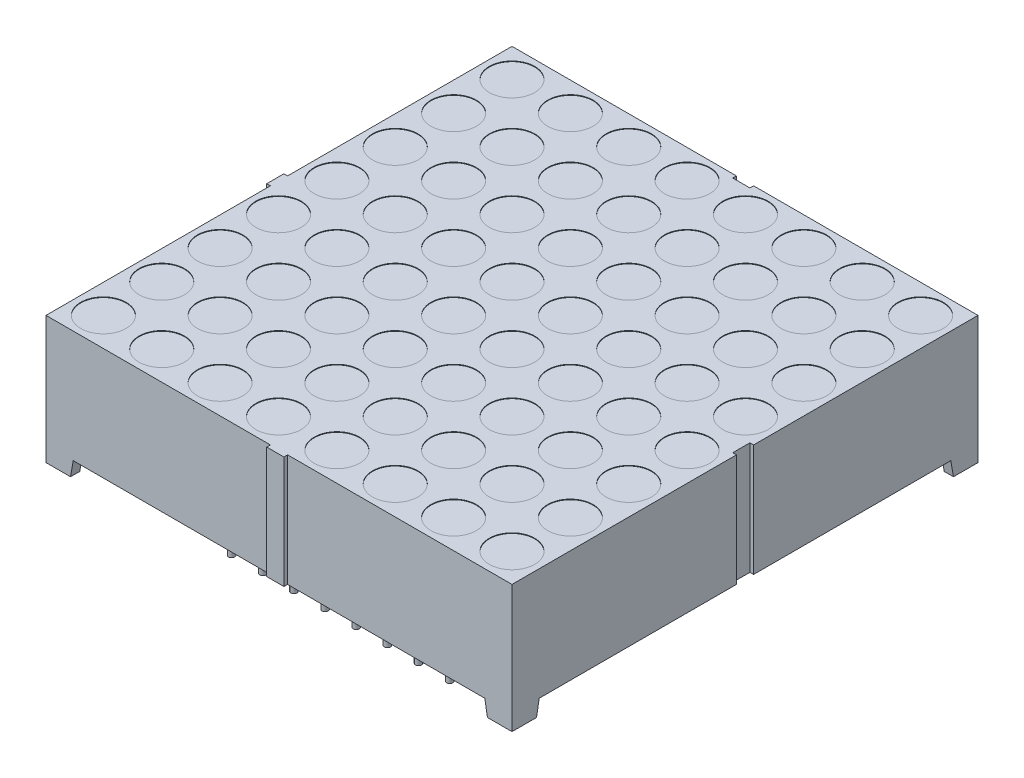
from build123d import *
from build123d.topology import SkipClean

# Parameters (mm, degrees)
EXTRUDE1_DEPTH     = 19
CUT_EXTRUDE1_DEPTH = 39
SKETCH2_R          = 1.85
CUT_EXTRUDE2_DEPTH = 0.05
SKETCH4_R          = 0.25
EXTRUDE2_DEPTH     = 1.25
SKETCH4_3_R        = 0.25
EXTRUDE3_DEPTH     = 4
SKETCH4_4_W        = 1.470408726
SKETCH4_4_H        = 1.470408726
CUT_EXTRUDE3_DEPTH = 1.25
SKETCH2_4_W        = 0.3
SKETCH2_4_H        = 1.4
SKETCH2_4_W_2      = 1.4
SKETCH2_4_H_2      = 0.3
CUT_EXTRUDE5_DEPTH = 15.4
SKETCH2_5_W        = 0.3
SKETCH2_5_H        = 1.4
SKETCH2_5_W_2      = 1.4
SKETCH2_5_H_2      = 0.3
EXTRUDE4_DEPTH     = 9.15
SKETCH5_W          = 0.026582278
SKETCH5_H          = 0.025316456
CUT_EXTRUDE6_DEPTH = 0.01


with BuildPart() as part:
    # Sketch1 → Extrude1 (new body, symmetric)
    with BuildSketch(Plane(origin=(0, 0, 0), x_dir=(0, 0, -1), z_dir=(1, 0, 0))):
        Polygon((19, 5.2), (-19, 5.2), (14.432692308, -3.95), (16.779591274, -3.95), (16.898590362, -4.624877362), (19, -5.2), align=None)
        Polygon((14.432692308, -3.95), (-19, 5.2), (-19, -5.2), (-17, -5.2), (-16.779591274, -3.95), align=None)
        Polygon((19, -5.2), (16.898590362, -4.624877362), (17, -5.2), align=None)
    extrude(amount=EXTRUDE1_DEPTH, both=True)

    # Sketch3 → Cut-Extrude1 (cut, through all)
    with BuildSketch(Plane.XY.offset(19)):
        Polygon((-16.779591274, -3.95), (-17, -5.2), (17, -5.2), (16.779591274, -3.95), align=None)
    extrude(amount=-CUT_EXTRUDE1_DEPTH, mode=Mode.SUBTRACT)

    # Sketch2 → Cut-Extrude2 (cut)
    with BuildSketch(Plane(origin=(0, 5.2, 0), x_dir=(-1, 0, 0), z_dir=(0, 1, 0))):
        with Locations(Location((7.14, 11.9, 0), (0, 0, 90))):  # turned: the seam where the file's is
            Circle(SKETCH2_R)
        with Locations(Location((7.14, -7.14, 0), (0, 0, 90))):  # turned: the seam where the file's is
            Circle(SKETCH2_R)
        with Locations(Location((7.14, -2.38, 0), (0, 0, 90))):  # turned: the seam where the file's is
            Circle(SKETCH2_R)
        with Locations(Location((7.14, -11.9, 0), (0, 0, 90))):  # turned: the seam where the file's is
            Circle(SKETCH2_R)
        with Locations(Location((7.14, 2.38, 0), (0, 0, 90))):  # turned: the seam where the file's is
            Circle(SKETCH2_R)
        with Locations(Location((7.14, 16.66, 0), (0, 0, 90))):  # turned: the seam where the file's is
            Circle(SKETCH2_R)
        with Locations(Location((7.14, 7.14, 0), (0, 0, 90))):  # turned: the seam where the file's is
            Circle(SKETCH2_R)
        with Locations(Location((2.38, -2.38, 0), (0, 0, 90))):  # turned: the seam where the file's is
            Circle(SKETCH2_R)
        with Locations(Location((2.38, 2.38, 0), (0, 0, 90))):  # turned: the seam where the file's is
            Circle(SKETCH2_R)
        with Locations(Location((2.38, 11.9, 0), (0, 0, 90))):  # turned: the seam where the file's is
            Circle(SKETCH2_R)
        with Locations(Location((2.38, 16.66, 0), (0, 0, 90))):  # turned: the seam where the file's is
            Circle(SKETCH2_R)
        with Locations(Location((2.38, -7.14, 0), (0, 0, 90))):  # turned: the seam where the file's is
            Circle(SKETCH2_R)
        with Locations(Location((2.38, -11.9, 0), (0, 0, 90))):  # turned: the seam where the file's is
            Circle(SKETCH2_R)
        with Locations(Location((2.38, 7.14, 0), (0, 0, 90))):  # turned: the seam where the file's is
            Circle(SKETCH2_R)
        with Locations(Location((11.9, -2.38, 0), (0, 0, 90))):  # turned: the seam where the file's is
            Circle(SKETCH2_R)
        with Locations(Location((11.9, 2.38, 0), (0, 0, 90))):  # turned: the seam where the file's is
            Circle(SKETCH2_R)
        with Locations(Location((11.9, 11.9, 0), (0, 0, 90))):  # turned: the seam where the file's is
            Circle(SKETCH2_R)
        with Locations(Location((11.9, 16.66, 0), (0, 0, 90))):  # turned: the seam where the file's is
            Circle(SKETCH2_R)
        with Locations(Location((11.9, -7.14, 0), (0, 0, 90))):  # turned: the seam where the file's is
            Circle(SKETCH2_R)
        with Locations(Location((11.9, -11.9, 0), (0, 0, 90))):  # turned: the seam where the file's is
            Circle(SKETCH2_R)
        with Locations(Location((11.9, 7.14, 0), (0, 0, 90))):  # turned: the seam where the file's is
            Circle(SKETCH2_R)
        with Locations(Location((16.66, -2.38, 0), (0, 0, 90))):  # turned: the seam where the file's is
            Circle(SKETCH2_R)
        with Locations(Location((16.66, 2.38, 0), (0, 0, 90))):  # turned: the seam where the file's is
            Circle(SKETCH2_R)
        with Locations(Location((16.66, 11.9, 0), (0, 0, 90))):  # turned: the seam where the file's is
            Circle(SKETCH2_R)
        with Locations(Location((16.66, 16.66, 0), (0, 0, 90))):  # turned: the seam where the file's is
            Circle(SKETCH2_R)
        with Locations(Location((16.66, -7.14, 0), (0, 0, 90))):  # turned: the seam where the file's is
            Circle(SKETCH2_R)
        with Locations(Location((16.66, -11.9, 0), (0, 0, 90))):  # turned: the seam where the file's is
            Circle(SKETCH2_R)
        with Locations(Location((16.66, 7.14, 0), (0, 0, 90))):  # turned: the seam where the file's is
            Circle(SKETCH2_R)
        with Locations(Location((-7.14, -16.66, 0), (0, 0, 90))):  # turned: the seam where the file's is
            Circle(SKETCH2_R)
        with Locations(Location((-11.9, -16.66, 0), (0, 0, 90))):  # turned: the seam where the file's is
            Circle(SKETCH2_R)
        with Locations(Location((-11.9, 7.14, 0), (0, 0, 90))):  # turned: the seam where the file's is
            Circle(SKETCH2_R)
        with Locations(Location((-11.9, -11.9, 0), (0, 0, 90))):  # turned: the seam where the file's is
            Circle(SKETCH2_R)
        with Locations(Location((-11.9, -7.14, 0), (0, 0, 90))):  # turned: the seam where the file's is
            Circle(SKETCH2_R)
        with Locations(Location((-11.9, 16.66, 0), (0, 0, 90))):  # turned: the seam where the file's is
            Circle(SKETCH2_R)
        with Locations(Location((-11.9, 11.9, 0), (0, 0, 90))):  # turned: the seam where the file's is
            Circle(SKETCH2_R)
        with Locations(Location((-11.9, 2.38, 0), (0, 0, 90))):  # turned: the seam where the file's is
            Circle(SKETCH2_R)
        with Locations(Location((-11.9, -2.38, 0), (0, 0, 90))):  # turned: the seam where the file's is
            Circle(SKETCH2_R)
        with Locations(Location((-2.38, 7.14, 0), (0, 0, 90))):  # turned: the seam where the file's is
            Circle(SKETCH2_R)
        with Locations(Location((-2.38, -11.9, 0), (0, 0, 90))):  # turned: the seam where the file's is
            Circle(SKETCH2_R)
        with Locations(Location((-2.38, -7.14, 0), (0, 0, 90))):  # turned: the seam where the file's is
            Circle(SKETCH2_R)
        with Locations(Location((-2.38, 16.66, 0), (0, 0, 90))):  # turned: the seam where the file's is
            Circle(SKETCH2_R)
        with Locations(Location((-2.38, 11.9, 0), (0, 0, 90))):  # turned: the seam where the file's is
            Circle(SKETCH2_R)
        with Locations(Location((-2.38, 2.38, 0), (0, 0, 90))):  # turned: the seam where the file's is
            Circle(SKETCH2_R)
        with Locations(Location((-2.38, -2.38, 0), (0, 0, 90))):  # turned: the seam where the file's is
            Circle(SKETCH2_R)
        with Locations(Location((-7.14, 7.14, 0), (0, 0, 90))):  # turned: the seam where the file's is
            Circle(SKETCH2_R)
        with Locations(Location((-7.14, 16.66, 0), (0, 0, 90))):  # turned: the seam where the file's is
            Circle(SKETCH2_R)
        with Locations(Location((-7.14, 2.38, 0), (0, 0, 90))):  # turned: the seam where the file's is
            Circle(SKETCH2_R)
        with Locations(Location((-7.14, -11.9, 0), (0, 0, 90))):  # turned: the seam where the file's is
            Circle(SKETCH2_R)
        with Locations(Location((-7.14, -2.38, 0), (0, 0, 90))):  # turned: the seam where the file's is
            Circle(SKETCH2_R)
        with Locations(Location((-7.14, -7.14, 0), (0, 0, 90))):  # turned: the seam where the file's is
            Circle(SKETCH2_R)
        with Locations(Location((-7.14, 11.9, 0), (0, 0, 90))):  # turned: the seam where the file's is
            Circle(SKETCH2_R)
        with Locations(Location((16.66, -16.66, 0), (0, 0, 90))):  # turned: the seam where the file's is
            Circle(SKETCH2_R)
        with Locations(Location((11.9, -16.66, 0), (0, 0, 90))):  # turned: the seam where the file's is
            Circle(SKETCH2_R)
        with Locations(Location((-2.38, -16.66, 0), (0, 0, 90))):  # turned: the seam where the file's is
            Circle(SKETCH2_R)
        with Locations(Location((2.38, -16.66, 0), (0, 0, 90))):  # turned: the seam where the file's is
            Circle(SKETCH2_R)
        with Locations(Location((7.14, -16.66, 0), (0, 0, 90))):  # turned: the seam where the file's is
            Circle(SKETCH2_R)
        with Locations(Location((-16.66, -16.66, 0), (0, 0, 90))):  # turned: the seam where the file's is
            Circle(SKETCH2_R)
        with Locations(Location((-16.66, 7.14, 0), (0, 0, 90))):  # turned: the seam where the file's is
            Circle(SKETCH2_R)
        with Locations(Location((-16.66, -11.9, 0), (0, 0, 90))):  # turned: the seam where the file's is
            Circle(SKETCH2_R)
        with Locations(Location((-16.66, -7.14, 0), (0, 0, 90))):  # turned: the seam where the file's is
            Circle(SKETCH2_R)
        with Locations(Location((-16.66, 16.66, 0), (0, 0, 90))):  # turned: the seam where the file's is
            Circle(SKETCH2_R)
        with Locations(Location((-16.66, 11.9, 0), (0, 0, 90))):  # turned: the seam where the file's is
            Circle(SKETCH2_R)
        with Locations(Location((-16.66, 2.38, 0), (0, 0, 90))):  # turned: the seam where the file's is
            Circle(SKETCH2_R)
        with Locations(Location((-16.66, -2.38, 0), (0, 0, 90))):  # turned: the seam where the file's is
            Circle(SKETCH2_R)
    extrude(amount=-CUT_EXTRUDE2_DEPTH, mode=Mode.SUBTRACT)

    # Sketch4 → Extrude2 (add)
    with BuildSketch(Plane.XZ.offset(5.2)):
        with Locations((-8.89, 13.97)):
            Circle(SKETCH4_R)
        with Locations(Location((-6.35, 13.97, 0), (0, 0, 270))):  # turned: the seam where the file's is
            Circle(SKETCH4_R)
        with Locations(Location((-3.81, 13.97, 0), (0, 0, 270))):  # turned: the seam where the file's is
            Circle(SKETCH4_R)
        with Locations(Location((6.35, 13.97, 0), (0, 0, 270))):  # turned: the seam where the file's is
            Circle(SKETCH4_R)
        with Locations(Location((-1.27, 13.97, 0), (0, 0, 270))):  # turned: the seam where the file's is
            Circle(SKETCH4_R)
        with Locations(Location((1.27, 13.97, 0), (0, 0, 270))):  # turned: the seam where the file's is
            Circle(SKETCH4_R)
        with Locations(Location((3.81, 13.97, 0), (0, 0, 270))):  # turned: the seam where the file's is
            Circle(SKETCH4_R)
        with Locations(Location((3.81, -13.97, 0), (0, 0, 270))):  # turned: the seam where the file's is
            Circle(SKETCH4_R)
        with Locations(Location((1.27, -13.97, 0), (0, 0, 270))):  # turned: the seam where the file's is
            Circle(SKETCH4_R)
        with Locations(Location((-1.27, -13.97, 0), (0, 0, 270))):  # turned: the seam where the file's is
            Circle(SKETCH4_R)
        with Locations(Location((6.35, -13.97, 0), (0, 0, 270))):  # turned: the seam where the file's is
            Circle(SKETCH4_R)
        with Locations(Location((-3.81, -13.97, 0), (0, 0, 270))):  # turned: the seam where the file's is
            Circle(SKETCH4_R)
        with Locations(Location((-6.35, -13.97, 0), (0, 0, 270))):  # turned: the seam where the file's is
            Circle(SKETCH4_R)
        with Locations(Location((-8.89, -13.97, 0), (0, 0, 270))):  # turned: the seam where the file's is
            Circle(SKETCH4_R)
        with Locations(Location((8.89, 13.97, 0), (0, 0, 270))):  # turned: the seam where the file's is
            Circle(SKETCH4_R)
        with Locations(Location((8.89, -13.97, 0), (0, 0, 270))):  # turned: the seam where the file's is
            Circle(SKETCH4_R)
    extrude(amount=-EXTRUDE2_DEPTH)

    # Sketch4_3 → Extrude3 (add)
    with SkipClean():  # keep this step's faces unmerged: merging them makes the solid invalid here
        with BuildSketch(Plane.XZ.offset(5.2)):
            with Locations((-8.89, 13.97)):
                Circle(SKETCH4_3_R)
            with Locations((-6.35, 13.97)):
                Circle(SKETCH4_3_R)
            with Locations((-3.81, 13.97)):
                Circle(SKETCH4_3_R)
            with Locations((6.35, 13.97)):
                Circle(SKETCH4_3_R)
            with Locations((-1.27, 13.97)):
                Circle(SKETCH4_3_R)
            with Locations((1.27, 13.97)):
                Circle(SKETCH4_3_R)
            with Locations(Location((3.81, 13.97, 0), (0, 0, 270))):  # turned: the seam where the file's is
                Circle(SKETCH4_3_R)
            with Locations(Location((3.81, -13.97, 0), (0, 0, 180))):  # turned: the seam where the file's is
                Circle(SKETCH4_3_R)
            with Locations(Location((1.27, -13.97, 0), (0, 0, 180))):  # turned: the seam where the file's is
                Circle(SKETCH4_3_R)
            with Locations(Location((-1.27, -13.97, 0), (0, 0, 180))):  # turned: the seam where the file's is
                Circle(SKETCH4_3_R)
            with Locations(Location((6.35, -13.97, 0), (0, 0, 180))):  # turned: the seam where the file's is
                Circle(SKETCH4_3_R)
            with Locations(Location((-3.81, -13.97, 0), (0, 0, 270))):  # turned: the seam where the file's is
                Circle(SKETCH4_3_R)
            with Locations(Location((-6.35, -13.97, 0), (0, 0, 270))):  # turned: the seam where the file's is
                Circle(SKETCH4_3_R)
            with Locations(Location((-8.89, -13.97, 0), (0, 0, 270))):  # turned: the seam where the file's is
                Circle(SKETCH4_3_R)
            with Locations(Location((8.89, 13.97, 0), (0, 0, 270))):  # turned: the seam where the file's is
                Circle(SKETCH4_3_R)
            with Locations(Location((8.89, -13.97, 0), (0, 0, 270))):  # turned: the seam where the file's is
                Circle(SKETCH4_3_R)
        extrude(amount=EXTRUDE3_DEPTH)

    # Sketch4_4 → Cut-Extrude3 (cut)
    with SkipClean():  # keep this step's faces unmerged: merging them makes the solid invalid here
        with BuildSketch(Plane.XZ.offset(5.2)):
            with Locations((-17.514795637, 17.514795637)):
                Rectangle(SKETCH4_4_W, SKETCH4_4_H)
            with Locations((17.514795637, 17.514795637)):
                Rectangle(SKETCH4_4_W, SKETCH4_4_H)
            with Locations((17.514795637, -17.514795637)):
                Rectangle(SKETCH4_4_W, SKETCH4_4_H)
            with Locations((-17.514795637, -17.514795637)):
                Rectangle(SKETCH4_4_W, SKETCH4_4_H)
        extrude(amount=-CUT_EXTRUDE3_DEPTH, mode=Mode.SUBTRACT)

    # Sketch2_4 → Cut-Extrude5 (cut, through all)
    with SkipClean():  # keep this step's faces unmerged: merging them makes the solid invalid here
        with BuildSketch(Plane(origin=(0, 5.2, 0), x_dir=(-1, 0, 0), z_dir=(0, 1, 0))):
            with Locations((-18.85, 0)):
                Rectangle(SKETCH2_4_W, SKETCH2_4_H)
            with Locations((0, -18.85)):
                Rectangle(SKETCH2_4_W_2, SKETCH2_4_H_2)
        extrude(amount=-CUT_EXTRUDE5_DEPTH, mode=Mode.SUBTRACT)

    # Sketch2_5 → Extrude4 (add)
    with SkipClean():  # keep this step's faces unmerged: merging them makes the solid invalid here
        with BuildSketch(Plane(origin=(0, 5.2, 0), x_dir=(-1, 0, 0), z_dir=(0, 1, 0))):
            with Locations((19.15, 0)):
                Rectangle(SKETCH2_5_W, SKETCH2_5_H)
            with Locations((0, 19.15)):
                Rectangle(SKETCH2_5_W_2, SKETCH2_5_H_2)
        extrude(amount=-EXTRUDE4_DEPTH)

    # Sketch5 → Cut-Extrude6 (cut)
    with SkipClean():  # keep this step's faces unmerged: merging them makes the solid invalid here
        with BuildSketch(Plane.XZ.offset(3.95)):
            Polygon((-16.512571084, 0.692786076), (-16.587254628, 0.716243355), (-16.587254628, 0.740986235), (-16.536918394, 0.757402374), (-16.587254628, 0.772928481), (-16.587254628, 0.798660285), (-16.512571084, 0.8219), (-16.512571084, 0.796721994), (-16.56405447, 0.783727532), (-16.512571084, 0.767311393), (-16.512571084, 0.745812184), (-16.56405447, 0.729494937), (-16.512571084, 0.716678481), align=None)
            Polygon((-16.512571084, 0.558608861), (-16.587254628, 0.58206614), (-16.587254628, 0.606809019), (-16.536918394, 0.623225159), (-16.587254628, 0.638751266), (-16.587254628, 0.66448307), (-16.512571084, 0.687722785), (-16.512571084, 0.662544779), (-16.56405447, 0.649550317), (-16.512571084, 0.633134178), (-16.512571084, 0.611634969), (-16.56405447, 0.595317722), (-16.512571084, 0.582501266), align=None)
            Polygon((-16.512571084, 0.424431646), (-16.587254628, 0.447888924), (-16.587254628, 0.472631804), (-16.536918394, 0.489047943), (-16.587254628, 0.504574051), (-16.587254628, 0.530305855), (-16.512571084, 0.55354557), (-16.512571084, 0.528367564), (-16.56405447, 0.515373102), (-16.512571084, 0.498956962), (-16.512571084, 0.477457754), (-16.56405447, 0.461140507), (-16.512571084, 0.448324051), align=None)
            with Locations((-16.573963489, 0.396583545)):
                Rectangle(SKETCH5_W, SKETCH5_H)
            with BuildLine():
                add(Edge.make_bspline(
                    [(-16.556083742, 0.280127848), (-16.557305876, 0.280164347), (-16.559705739, 0.280236017), (-16.563213426, 0.280845603), (-16.56653773, 0.281839571), (-16.569701876, 0.28321191), (-16.572671364, 0.285005366), (-16.575474256, 0.287188637), (-16.5780788, 0.28977752), (-16.580515175, 0.292724324), (-16.582697286, 0.296021267), (-16.58460332, 0.299618981), (-16.586197991, 0.303499008), (-16.587537056, 0.307647219), (-16.588525489, 0.312093766), (-16.589249477, 0.316811264), (-16.589722795, 0.321804692), (-16.589764762, 0.325228269), (-16.589786274, 0.32698307)],
                    knots=[0, 0, 0, 0, 0.907312236, 1.78165839, 2.635367075, 3.479697475, 4.336364812, 5.205276731, 6.11257575, 7.058770404, 8.040786331, 9.044147278, 10.078219212, 11.153049307, 12.278104542, 13.457648573, 14.696882856, 16, 16, 16, 16], degree=3))
                add(Edge.make_bspline(
                    [(-16.589786274, 0.32698307), (-16.589762202, 0.329001325), (-16.589715577, 0.332910508), (-16.589286978, 0.338574033), (-16.588640839, 0.34384207), (-16.587674297, 0.348737785), (-16.586473532, 0.353342384), (-16.58518224, 0.357775652), (-16.583717825, 0.362056964), (-16.582617667, 0.364830053), (-16.582072666, 0.366203798)],
                    knots=[0, 0, 0, 0, 1.203215828, 2.33052265, 3.384689099, 4.366106119, 5.303329643, 6.221311756, 7.118865988, 8, 8, 8, 8], degree=3))
                Line((-16.582072666, 0.366203798), (-16.558140704, 0.366203798))
                Line((-16.558140704, 0.366203798), (-16.558140704, 0.363355697))
                add(Edge.make_bspline(
                    [(-16.558140704, 0.363355697), (-16.559222159, 0.361990382), (-16.56137872, 0.35926777), (-16.564141325, 0.354834537), (-16.566543488, 0.350186891), (-16.56851749, 0.34534142), (-16.570103814, 0.340444576), (-16.571197342, 0.335569198), (-16.57194469, 0.330803611), (-16.572025197, 0.327645041), (-16.572064755, 0.326093038)],
                    knots=[0, 0, 0, 0, 1.030622468, 2.055194264, 3.087043286, 4.125157485, 5.149848264, 6.130935704, 7.081611712, 8, 8, 8, 8], degree=3))
                add(Edge.make_bspline(
                    [(-16.572064755, 0.326093038), (-16.57206386, 0.32566426), (-16.572061945, 0.324746278), (-16.571933102, 0.323278241), (-16.571839939, 0.321619642), (-16.571630721, 0.319840776), (-16.571412138, 0.318049958), (-16.571031818, 0.316395298), (-16.570669979, 0.314891659), (-16.570301802, 0.313985177), (-16.570126464, 0.313553481)],
                    knots=[0, 0, 0, 0, 0.806378557, 1.726393851, 2.771014456, 3.931269413, 5.096090628, 6.161710732, 7.124547685, 8, 8, 8, 8], degree=3))
                add(Edge.make_bspline(
                    [(-16.570126464, 0.313553481), (-16.56989864, 0.313073695), (-16.569450918, 0.312130811), (-16.568633311, 0.310835892), (-16.567762009, 0.30965322), (-16.56679659, 0.308591759), (-16.565618682, 0.307741492), (-16.564217826, 0.307113291), (-16.562567525, 0.306770197), (-16.561392515, 0.306730903), (-16.560771242, 0.306710127)],
                    knots=[0, 0, 0, 0, 1.024407818, 2.013179384, 2.949802342, 3.859052226, 4.77034807, 5.732977883, 6.801339628, 8, 8, 8, 8], degree=3))
                add(Edge.make_bspline(
                    [(-16.560771242, 0.306710127), (-16.560225346, 0.306741569), (-16.559151953, 0.306803392), (-16.557623957, 0.307385184), (-16.55620208, 0.308268082), (-16.554941365, 0.309555104), (-16.553783927, 0.311149181), (-16.55281363, 0.313104918), (-16.551933556, 0.315357897), (-16.551516287, 0.317002356), (-16.55129735, 0.31786519)],
                    knots=[0, 0, 0, 0, 0.825212765, 1.622611382, 2.449701629, 3.348069183, 4.336544339, 5.428209675, 6.6506027, 8, 8, 8, 8], degree=3))
                add(Edge.make_bspline(
                    [(-16.55129735, 0.31786519), (-16.550849609, 0.319833917), (-16.549932419, 0.323866825), (-16.548785312, 0.330014934), (-16.547519239, 0.336145162), (-16.546309698, 0.340103874), (-16.545719818, 0.342034494)],
                    knots=[0, 0, 0, 0, 0.976104583, 1.999535498, 3.024395274, 4, 4, 4, 4], degree=3))
                add(Edge.make_bspline(
                    [(-16.545719818, 0.342034494), (-16.545366825, 0.34307301), (-16.544679692, 0.345094578), (-16.543518067, 0.347986122), (-16.542248115, 0.350647235), (-16.540892984, 0.353087345), (-16.539418986, 0.355286667), (-16.537885597, 0.357281857), (-16.536231759, 0.359025383), (-16.534499839, 0.360573067), (-16.532647837, 0.361896381), (-16.5307037, 0.363051131), (-16.528643235, 0.364026767), (-16.526481947, 0.36483565), (-16.524203078, 0.365452723), (-16.521826204, 0.365873979), (-16.519342844, 0.366172368), (-16.517648491, 0.366193179), (-16.5167839, 0.366203798)],
                    knots=[0, 0, 0, 0, 1.287286806, 2.505824366, 3.654938963, 4.74627059, 5.778586806, 6.75996495, 7.696030012, 8.595059759, 9.482019644, 10.363222407, 11.245851011, 12.154256429, 13.068444161, 14.012503255, 14.985824751, 16, 16, 16, 16], degree=3))
                add(Edge.make_bspline(
                    [(-16.5167839, 0.366203798), (-16.515627756, 0.366166496), (-16.513352483, 0.366093086), (-16.510023439, 0.365491658), (-16.506874702, 0.364465068), (-16.503871239, 0.363079004), (-16.501058153, 0.361250376), (-16.498379606, 0.359065582), (-16.495908014, 0.356441534), (-16.493607681, 0.353464413), (-16.491528282, 0.350177029), (-16.489697726, 0.346638045), (-16.488161074, 0.342868756), (-16.48688718, 0.338883209), (-16.485932509, 0.33466474), (-16.485213578, 0.330227508), (-16.484800396, 0.325553719), (-16.484749146, 0.322362297), (-16.484722983, 0.32073307)],
                    knots=[0, 0, 0, 0, 0.894990994, 1.761326291, 2.609044902, 3.454222546, 4.315366365, 5.200560057, 6.125081389, 7.100429509, 8.110379559, 9.133447974, 10.182136699, 11.259192205, 12.370181258, 13.528580438, 14.738335141, 16, 16, 16, 16], degree=3))
                add(Edge.make_bspline(
                    [(-16.484722983, 0.32073307), (-16.484745174, 0.319064383), (-16.484789519, 0.315729838), (-16.485167497, 0.310748396), (-16.485722725, 0.305787894), (-16.486564431, 0.300924063), (-16.487540848, 0.296233508), (-16.488636643, 0.291820272), (-16.489874608, 0.287740812), (-16.490828953, 0.285167148), (-16.491289438, 0.283925317)],
                    knots=[0, 0, 0, 0, 1.065403572, 2.129000689, 3.188532477, 4.251604565, 5.279552602, 6.247508681, 7.154397237, 8, 8, 8, 8], degree=3))
                Line((-16.491289438, 0.283925317), (-16.513836907, 0.283925317))
                Line((-16.513836907, 0.283925317), (-16.513836907, 0.28675364))
                add(Edge.make_bspline(
                    [(-16.513836907, 0.28675364), (-16.51303656, 0.287826544), (-16.51139983, 0.290020663), (-16.509316158, 0.293680299), (-16.507358292, 0.297638535), (-16.505674133, 0.301917366), (-16.504214652, 0.306376393), (-16.503195486, 0.310959352), (-16.502553676, 0.315585515), (-16.502480901, 0.318687226), (-16.502444502, 0.320238608)],
                    knots=[0, 0, 0, 0, 0.892283326, 1.824742884, 2.804416662, 3.836872171, 4.8899239, 5.931447339, 6.965372909, 8, 8, 8, 8], degree=3))
                add(Edge.make_bspline(
                    [(-16.502444502, 0.320238608), (-16.502465954, 0.321334276), (-16.502508856, 0.323525492), (-16.50289954, 0.326793701), (-16.503530434, 0.330035762), (-16.504349716, 0.332076284), (-16.504758584, 0.333094621)],
                    knots=[0, 0, 0, 0, 0.999146175, 1.998183711, 3.000980573, 4, 4, 4, 4], degree=3))
                add(Edge.make_bspline(
                    [(-16.504758584, 0.333094621), (-16.504960051, 0.333528124), (-16.50536285, 0.334394841), (-16.506135414, 0.335601486), (-16.507064225, 0.336706155), (-16.508116217, 0.337698232), (-16.50927259, 0.33856663), (-16.510547417, 0.339181981), (-16.511910331, 0.339557854), (-16.512845562, 0.339600012), (-16.513322666, 0.339621519)],
                    knots=[0, 0, 0, 0, 1.00524851, 2.009826503, 3.004679593, 4.035271301, 5.048246368, 6.034938417, 6.997532266, 8, 8, 8, 8], degree=3))
                add(Edge.make_bspline(
                    [(-16.513322666, 0.339621519), (-16.513960831, 0.339587081), (-16.515180307, 0.339521273), (-16.516896103, 0.338914689), (-16.518374537, 0.337929855), (-16.519369457, 0.336769251), (-16.520066895, 0.335652121), (-16.520577406, 0.334616461), (-16.521060764, 0.333407234), (-16.521558233, 0.332035987), (-16.52204942, 0.33049966), (-16.522524967, 0.328791103), (-16.522974263, 0.326908386), (-16.523260453, 0.325592511), (-16.523409691, 0.324906329)],
                    knots=[0, 0, 0, 0, 1.173816843, 2.243057204, 3.312297565, 4.415174738, 5.03266065, 5.73970059, 6.541434878, 7.433956553, 8.430083051, 9.515931566, 10.70464786, 12, 12, 12, 12], degree=3))
                add(Edge.make_bspline(
                    [(-16.523409691, 0.324906329), (-16.523785753, 0.32307354), (-16.524524631, 0.319472514), (-16.525628119, 0.314071331), (-16.526903088, 0.308568557), (-16.528051891, 0.304903231), (-16.528650989, 0.302991773)],
                    knots=[0, 0, 0, 0, 0.995744513, 1.956417928, 2.934277412, 4, 4, 4, 4], degree=3))
                add(Edge.make_bspline(
                    [(-16.528650989, 0.302991773), (-16.528970233, 0.302045218), (-16.529594726, 0.300193605), (-16.530681008, 0.297552975), (-16.531854991, 0.295105916), (-16.533096522, 0.292838883), (-16.534440488, 0.290764913), (-16.535863135, 0.288870231), (-16.537390044, 0.287186413), (-16.539003272, 0.285688847), (-16.540713372, 0.284369687), (-16.542552445, 0.283237389), (-16.544501247, 0.282265161), (-16.546587447, 0.281495556), (-16.548782034, 0.280877536), (-16.551113402, 0.280454439), (-16.553557779, 0.280160455), (-16.555232356, 0.280138839), (-16.556083742, 0.280127848)],
                    knots=[0, 0, 0, 0, 1.237467875, 2.420686895, 3.535046182, 4.599015201, 5.620884487, 6.594603852, 7.531477383, 8.433220087, 9.318759595, 10.202828513, 11.105163009, 12.01247538, 12.953896178, 13.926381251, 14.945733412, 16, 16, 16, 16], degree=3))
            make_face()
            with BuildLine():
                Line((-16.587254628, 0.187722785), (-16.587254628, 0.211773418))
                Line((-16.587254628, 0.211773418), (-16.57942235, 0.211773418))
                add(Edge.make_bspline(
                    [(-16.57942235, 0.211773418), (-16.580230908, 0.212866727), (-16.581789797, 0.21497461), (-16.583870014, 0.218147635), (-16.58564528, 0.221173726), (-16.587204501, 0.224087216), (-16.588379886, 0.22710942), (-16.589207953, 0.230340934), (-16.589707725, 0.233843758), (-16.589759509, 0.236270653), (-16.589786274, 0.237525)],
                    knots=[0, 0, 0, 0, 1.150872466, 2.218865267, 3.209461834, 4.120482262, 5.012764827, 5.946708227, 6.938749913, 8, 8, 8, 8], degree=3))
                add(Edge.make_bspline(
                    [(-16.589786274, 0.237525), (-16.589763555, 0.238541352), (-16.589719314, 0.240520483), (-16.589374437, 0.243397723), (-16.588836785, 0.246105351), (-16.588029194, 0.24862039), (-16.587063391, 0.25098438), (-16.585783433, 0.253121929), (-16.584353259, 0.255125531), (-16.582646213, 0.256907204), (-16.58074848, 0.258522825), (-16.57861602, 0.259905375), (-16.576283095, 0.261083086), (-16.573731241, 0.262024184), (-16.570972937, 0.262779273), (-16.56799369, 0.263303206), (-16.564806562, 0.263623798), (-16.562611432, 0.263655737), (-16.561483267, 0.263672152)],
                    knots=[0, 0, 0, 0, 1.109008058, 2.159558935, 3.158726032, 4.116861086, 5.039058877, 5.938775559, 6.82970133, 7.720510853, 8.624361809, 9.544451588, 10.487360536, 11.471068125, 12.508000841, 13.604731202, 14.768976642, 16, 16, 16, 16], degree=3))
                Line((-16.561483267, 0.263672152), (-16.512571084, 0.263672152))
                Line((-16.512571084, 0.263672152), (-16.512571084, 0.239621519))
                Line((-16.512571084, 0.239621519), (-16.550150198, 0.239621519))
                add(Edge.make_bspline(
                    [(-16.550150198, 0.239621519), (-16.551066669, 0.239619884), (-16.552820884, 0.239616753), (-16.555326691, 0.239534414), (-16.557594864, 0.239413514), (-16.559636892, 0.239274809), (-16.561483643, 0.239021792), (-16.563149804, 0.238644084), (-16.564669406, 0.238173258), (-16.565576107, 0.237708939), (-16.56601254, 0.237485443)],
                    knots=[0, 0, 0, 0, 1.361401701, 2.605856924, 3.723918663, 4.735739235, 5.645738665, 6.489217889, 7.27279937, 8, 8, 8, 8], degree=3))
                add(Edge.make_bspline(
                    [(-16.56601254, 0.237485443), (-16.566411254, 0.237255437), (-16.567195094, 0.236803263), (-16.568201272, 0.235882973), (-16.569045539, 0.234804231), (-16.569701568, 0.233526627), (-16.570200517, 0.232040079), (-16.570540753, 0.230312148), (-16.570756255, 0.228326786), (-16.570784163, 0.226917768), (-16.570798932, 0.226172152)],
                    knots=[0, 0, 0, 0, 0.849138082, 1.669332372, 2.503455908, 3.370611167, 4.311442699, 5.394692208, 6.621337967, 8, 8, 8, 8], degree=3))
                add(Edge.make_bspline(
                    [(-16.570798932, 0.226172152), (-16.570781575, 0.225630868), (-16.570745888, 0.224517951), (-16.570513442, 0.222806638), (-16.570156767, 0.221010061), (-16.569496911, 0.218495479), (-16.568310732, 0.215328851), (-16.566956325, 0.21296955), (-16.56626966, 0.211773418)],
                    knots=[0, 0, 0, 0, 0.638127216, 1.312033637, 2.033062677, 2.79661882, 4.375931797, 6, 6, 6, 6], degree=3))
                Line((-16.56626966, 0.211773418), (-16.512571084, 0.211773418))
                Line((-16.512571084, 0.211773418), (-16.512571084, 0.187722785))
                Line((-16.512571084, 0.187722785), (-16.587254628, 0.187722785))
            make_face()
            with BuildLine():
                Line((-16.587254628, 0.090254431), (-16.587254628, 0.114305064))
                Line((-16.587254628, 0.114305064), (-16.549675514, 0.114305064))
                add(Edge.make_bspline(
                    [(-16.549675514, 0.114305064), (-16.548145471, 0.114329578), (-16.545094446, 0.114378462), (-16.541332036, 0.114660585), (-16.538489711, 0.115039107), (-16.53665183, 0.115408763), (-16.535103691, 0.115840463), (-16.534217932, 0.116252743), (-16.533813172, 0.11644114)],
                    knots=[0, 0, 0, 0, 1.709124929, 3.408128882, 4.211124727, 4.91016634, 5.501986363, 6, 6, 6, 6], degree=3))
                add(Edge.make_bspline(
                    [(-16.533813172, 0.11644114), (-16.533415119, 0.116685602), (-16.532634679, 0.117164906), (-16.531621666, 0.11810223), (-16.530792825, 0.119196116), (-16.530111275, 0.120466886), (-16.529640694, 0.121958083), (-16.529247464, 0.123674823), (-16.529080555, 0.125661441), (-16.529045395, 0.127068711), (-16.52902678, 0.127813766)],
                    knots=[0, 0, 0, 0, 0.86006424, 1.686277094, 2.52783008, 3.38194165, 4.331801563, 5.402842185, 6.624978739, 8, 8, 8, 8], degree=3))
                add(Edge.make_bspline(
                    [(-16.52902678, 0.127813766), (-16.529083517, 0.128945588), (-16.529199371, 0.131256682), (-16.529910878, 0.134118876), (-16.530729837, 0.13644948), (-16.531488668, 0.138302004), (-16.53246011, 0.140210635), (-16.533181932, 0.141490047), (-16.533556052, 0.142153165)],
                    knots=[0, 0, 0, 0, 1.338371478, 2.732853438, 3.468019217, 4.261884641, 5.099136535, 6, 6, 6, 6], degree=3))
                Line((-16.533556052, 0.142153165), (-16.587254628, 0.142153165))
                Line((-16.587254628, 0.142153165), (-16.587254628, 0.166203798))
                Line((-16.587254628, 0.166203798), (-16.512571084, 0.166203798))
                Line((-16.512571084, 0.166203798), (-16.512571084, 0.142153165))
                Line((-16.512571084, 0.142153165), (-16.520403362, 0.142153165))
                add(Edge.make_bspline(
                    [(-16.520403362, 0.142153165), (-16.519597211, 0.141095758), (-16.518027989, 0.139037454), (-16.515987568, 0.135858216), (-16.514188799, 0.132774318), (-16.512675982, 0.129721308), (-16.511469207, 0.126606353), (-16.510658218, 0.123343595), (-16.510114416, 0.119927189), (-16.510064722, 0.117590473), (-16.510039438, 0.116401583)],
                    knots=[0, 0, 0, 0, 1.126119141, 2.192057864, 3.198061997, 4.149848529, 5.076251285, 6.021887753, 6.99356175, 8, 8, 8, 8], degree=3))
                add(Edge.make_bspline(
                    [(-16.510039438, 0.116401583), (-16.510064827, 0.115405311), (-16.510114391, 0.113460412), (-16.510424101, 0.110625652), (-16.510974765, 0.107954231), (-16.511772595, 0.105461957), (-16.512758207, 0.103119337), (-16.513989721, 0.100957392), (-16.515448145, 0.098965322), (-16.517109147, 0.097136921), (-16.518998874, 0.095506103), (-16.521116138, 0.094089067), (-16.523459235, 0.092909085), (-16.526019543, 0.091938373), (-16.528784653, 0.09116395), (-16.531780618, 0.090648819), (-16.534984797, 0.090295035), (-16.53720084, 0.090268236), (-16.538342445, 0.090254431)],
                    knots=[0, 0, 0, 0, 1.08848837, 2.124922927, 3.110950502, 4.063144162, 4.979605775, 5.882838355, 6.774625441, 7.671951181, 8.57587277, 9.494821853, 10.448322275, 11.435533005, 12.482327682, 13.580118324, 14.753386918, 16, 16, 16, 16], degree=3))
                Line((-16.538342445, 0.090254431), (-16.587254628, 0.090254431))
            make_face()
            Polygon((-16.587254628, -0.004682278), (-16.587254628, 0.067469621), (-16.487254628, 0.067469621), (-16.487254628, 0.042153165), (-16.568267286, 0.042153165), (-16.568267286, -0.004682278), align=None)
            Polygon((-16.587254628, -0.09202405), (-16.587254628, -0.019872152), (-16.487254628, -0.019872152), (-16.487254628, -0.09202405), (-16.50624197, -0.09202405), (-16.50624197, -0.045188607), (-16.523963489, -0.045188607), (-16.523963489, -0.088226582), (-16.542950831, -0.088226582), (-16.542950831, -0.045188607), (-16.568267286, -0.045188607), (-16.568267286, -0.09202405), align=None)
            with BuildLine():
                add(Edge.make_bspline(
                    [(-16.537353521, -0.208479746), (-16.538501209, -0.208460431), (-16.540774096, -0.208422179), (-16.544138902, -0.208126988), (-16.547404578, -0.207600962), (-16.550588826, -0.206921781), (-16.553667754, -0.205999275), (-16.556675331, -0.204917561), (-16.559580825, -0.203607916), (-16.562382259, -0.202103063), (-16.565054362, -0.200453591), (-16.567574571, -0.198678842), (-16.569957788, -0.196833063), (-16.572152682, -0.19484375), (-16.574194702, -0.192764568), (-16.576085516, -0.19058904), (-16.577788947, -0.188283975), (-16.578811831, -0.186676813), (-16.579323457, -0.185872943)],
                    knots=[0, 0, 0, 0, 1.105570398, 2.18947457, 3.250358341, 4.290584537, 5.323553275, 6.344225964, 7.367641686, 8.3905646, 9.405808457, 10.390761353, 11.358902336, 12.307789878, 13.241960776, 14.165076779, 15.082208636, 16, 16, 16, 16], degree=3))
                add(Edge.make_bspline(
                    [(-16.579323457, -0.185872943), (-16.580035597, -0.184633714), (-16.581463509, -0.182148935), (-16.5831321, -0.1781651), (-16.584536216, -0.174039618), (-16.58559064, -0.169689231), (-16.586317684, -0.165042222), (-16.586878491, -0.160040813), (-16.58718025, -0.154633223), (-16.58722927, -0.150898328), (-16.587254628, -0.148966297)],
                    knots=[0, 0, 0, 0, 0.896288622, 1.797150563, 2.705281913, 3.629615989, 4.602417572, 5.655716007, 6.787320449, 8, 8, 8, 8], degree=3))
                Line((-16.587254628, -0.148966297), (-16.587254628, -0.113543038))
                Line((-16.587254628, -0.113543038), (-16.487254628, -0.113543038))
                Line((-16.487254628, -0.113543038), (-16.487254628, -0.149975))
                add(Edge.make_bspline(
                    [(-16.487254628, -0.149975), (-16.487271239, -0.151953731), (-16.48730328, -0.15577046), (-16.48772087, -0.161287299), (-16.488317694, -0.166392507), (-16.489242565, -0.171077855), (-16.49035791, -0.17537786), (-16.491717039, -0.179303335), (-16.493215746, -0.182915109), (-16.49448944, -0.185093951), (-16.495106685, -0.186149841)],
                    knots=[0, 0, 0, 0, 1.267175336, 2.444223962, 3.542125549, 4.557526608, 5.500936977, 6.385043188, 7.217374394, 8, 8, 8, 8], degree=3))
                add(Edge.make_bspline(
                    [(-16.495106685, -0.186149841), (-16.495643226, -0.187000795), (-16.496710139, -0.188692919), (-16.498491992, -0.191094134), (-16.500448069, -0.193323561), (-16.502499887, -0.195452064), (-16.504702774, -0.197431882), (-16.507041481, -0.199275081), (-16.509519575, -0.200978898), (-16.512129044, -0.202536862), (-16.514859096, -0.203957677), (-16.517732155, -0.205146983), (-16.520710685, -0.206196332), (-16.523819648, -0.207001868), (-16.527027484, -0.207699782), (-16.530368828, -0.208134517), (-16.533821316, -0.208421128), (-16.536166206, -0.208460042), (-16.537353521, -0.208479746)],
                    knots=[0, 0, 0, 0, 0.964065863, 1.917049184, 2.86229036, 3.805247319, 4.749389377, 5.698846072, 6.657678277, 7.629829384, 8.610569287, 9.604676042, 10.607940105, 11.6349849, 12.681042988, 13.752616828, 14.862056989, 16, 16, 16, 16], degree=3))
            make_face()
            with BuildLine():
                add(Edge.make_bspline(
                    [(-16.537195293, -0.181897468), (-16.536390533, -0.181887227), (-16.534811949, -0.18186714), (-16.532496434, -0.181675572), (-16.530266784, -0.181416516), (-16.528132092, -0.180985462), (-16.526072522, -0.180485815), (-16.524115027, -0.179843666), (-16.522235454, -0.179119269), (-16.520457966, -0.178237631), (-16.518749583, -0.177263994), (-16.517164068, -0.176116501), (-16.515651182, -0.174868163), (-16.514223197, -0.173489877), (-16.512917301, -0.171946937), (-16.511687225, -0.170286834), (-16.510558899, -0.168486476), (-16.509898849, -0.167213488), (-16.509564755, -0.166569145)],
                    knots=[0, 0, 0, 0, 1.152093354, 2.259898929, 3.325467225, 4.364140538, 5.376172865, 6.358396836, 7.312077728, 8.257828931, 9.196960457, 10.124297759, 11.056236784, 12.004246951, 12.961658638, 13.947279359, 14.960983522, 16, 16, 16, 16], degree=3))
                add(Edge.make_bspline(
                    [(-16.509564755, -0.166569145), (-16.509258043, -0.165894248), (-16.508650118, -0.164556553), (-16.507918926, -0.162485731), (-16.50734609, -0.160396347), (-16.506915232, -0.158194748), (-16.506593301, -0.155724988), (-16.506396043, -0.152799406), (-16.506253873, -0.149343497), (-16.506246122, -0.146856782), (-16.50624197, -0.145524841)],
                    knots=[0, 0, 0, 0, 0.826967603, 1.639107464, 2.447640171, 3.242670507, 4.14065217, 5.225198036, 6.513753944, 8, 8, 8, 8], degree=3))
                Line((-16.50624197, -0.145524841), (-16.50624197, -0.138859493))
                Line((-16.50624197, -0.138859493), (-16.568267286, -0.138859493))
                Line((-16.568267286, -0.138859493), (-16.568267286, -0.145524841))
                add(Edge.make_bspline(
                    [(-16.568267286, -0.145524841), (-16.568262537, -0.146283048), (-16.568253367, -0.147746814), (-16.568210305, -0.149863057), (-16.568163418, -0.151828854), (-16.568046955, -0.153633724), (-16.567974309, -0.155292409), (-16.56779593, -0.15677919), (-16.56765375, -0.15812168), (-16.567386027, -0.159689276), (-16.566969844, -0.161542442), (-16.566291666, -0.163703702), (-16.56544127, -0.165844237), (-16.564756303, -0.16723281), (-16.564410483, -0.16793386)],
                    knots=[0, 0, 0, 0, 1.186793418, 2.291178421, 3.313283093, 4.264083014, 5.122158624, 5.910777728, 6.607099052, 7.234812932, 8.398911528, 9.577194775, 10.776795607, 12, 12, 12, 12], degree=3))
                add(Edge.make_bspline(
                    [(-16.564410483, -0.16793386), (-16.564068966, -0.168518976), (-16.563395452, -0.169672902), (-16.562261378, -0.171296407), (-16.561053653, -0.172804125), (-16.559765202, -0.174200137), (-16.558376961, -0.175463436), (-16.556910419, -0.176615455), (-16.555362441, -0.177645904), (-16.553168923, -0.178881293), (-16.550137987, -0.180104539), (-16.5461706, -0.181144081), (-16.541810837, -0.181780953), (-16.538773219, -0.181857635), (-16.537195293, -0.181897468)],
                    knots=[0, 0, 0, 0, 0.755160452, 1.489275589, 2.205657296, 2.907868421, 3.605098304, 4.296256403, 4.985378686, 5.676536785, 7.100390329, 8.614249252, 10.241231541, 12, 12, 12, 12], degree=3))
            make_face(mode=Mode.SUBTRACT)
            with Locations((-16.573963489, -0.240125316)):
                Rectangle(SKETCH5_W, SKETCH5_H)
            with BuildLine():
                add(Edge.make_bspline(
                    [(-16.589786274, -0.314769303), (-16.589764463, -0.313179191), (-16.589721651, -0.310058054), (-16.589244734, -0.305486713), (-16.588527039, -0.30112154), (-16.587506132, -0.296975232), (-16.586158636, -0.29306144), (-16.5845057, -0.289397803), (-16.582520516, -0.285990946), (-16.580941307, -0.283932299), (-16.580154153, -0.282906171)],
                    knots=[0, 0, 0, 0, 1.123670284, 2.205584497, 3.245308791, 4.249063313, 5.220352711, 6.167273909, 7.086481357, 8, 8, 8, 8], degree=3))
                add(Edge.make_bspline(
                    [(-16.580154153, -0.282906171), (-16.579299379, -0.281954423), (-16.577593136, -0.280054608), (-16.57462171, -0.277588675), (-16.571338665, -0.27546559), (-16.567736443, -0.273680037), (-16.563819714, -0.272249114), (-16.559575052, -0.27122598), (-16.555014271, -0.270606734), (-16.551866338, -0.270539569), (-16.55024909, -0.270505063)],
                    knots=[0, 0, 0, 0, 0.916457077, 1.82937027, 2.759194969, 3.714948755, 4.706655623, 5.743329475, 6.840637961, 8, 8, 8, 8], degree=3))
                add(Edge.make_bspline(
                    [(-16.55024909, -0.270505063), (-16.548545863, -0.270543823), (-16.545244783, -0.270618946), (-16.540472596, -0.271282706), (-16.536054915, -0.272352318), (-16.532003007, -0.273889876), (-16.528309815, -0.275820318), (-16.52493798, -0.278084811), (-16.521895056, -0.280705337), (-16.520149617, -0.282712475), (-16.519275989, -0.283717088)],
                    knots=[0, 0, 0, 0, 1.171797512, 2.271099083, 3.308930235, 4.294129479, 5.24602549, 6.17106565, 7.084581485, 8, 8, 8, 8], degree=3))
                add(Edge.make_bspline(
                    [(-16.519275989, -0.283717088), (-16.518507403, -0.284742959), (-16.516960947, -0.28680709), (-16.515060247, -0.290210595), (-16.513465461, -0.29383381), (-16.512217817, -0.297663381), (-16.511263911, -0.30163619), (-16.510540068, -0.305695849), (-16.510119509, -0.309842102), (-16.510066257, -0.312632303), (-16.510039438, -0.3140375)],
                    knots=[0, 0, 0, 0, 0.952130878, 1.915761808, 2.890227217, 3.891541892, 4.905612075, 5.925811839, 6.955400088, 8, 8, 8, 8], degree=3))
                add(Edge.make_bspline(
                    [(-16.510039438, -0.3140375), (-16.510056441, -0.315284218), (-16.510089873, -0.31773569), (-16.510411982, -0.321336737), (-16.510945101, -0.324791278), (-16.511683704, -0.32809621), (-16.512575307, -0.331270156), (-16.513614448, -0.334320333), (-16.514747716, -0.337280143), (-16.515632251, -0.339180712), (-16.516071875, -0.340125316)],
                    knots=[0, 0, 0, 0, 1.107648782, 2.178012834, 3.209595929, 4.211695017, 5.185427128, 6.137685403, 7.07440854, 8, 8, 8, 8], degree=3))
                Line((-16.516071875, -0.340125316), (-16.536621717, -0.340125316))
                Line((-16.536621717, -0.340125316), (-16.536621717, -0.336782753))
                add(Edge.make_bspline(
                    [(-16.536621717, -0.336782753), (-16.536204497, -0.336283209), (-16.535302783, -0.335203573), (-16.53388203, -0.333417157), (-16.532352437, -0.331268215), (-16.531460491, -0.329614679), (-16.53098485, -0.328732911)],
                    knots=[0, 0, 0, 0, 0.792826818, 1.713491785, 2.780691913, 4, 4, 4, 4], degree=3))
                add(Edge.make_bspline(
                    [(-16.53098485, -0.328732911), (-16.530542892, -0.327804976), (-16.529637032, -0.325903031), (-16.528804198, -0.323347026), (-16.528236472, -0.321155024), (-16.52798005, -0.319337488), (-16.527790489, -0.317403868), (-16.527770982, -0.316068626), (-16.527760957, -0.315382436)],
                    knots=[0, 0, 0, 0, 1.332524827, 2.731214173, 3.480270227, 4.267952375, 5.109889624, 6, 6, 6, 6], degree=3))
                add(Edge.make_bspline(
                    [(-16.527760957, -0.315382436), (-16.527780507, -0.314616881), (-16.527818393, -0.31313327), (-16.528095449, -0.310971762), (-16.528573707, -0.30895335), (-16.529213807, -0.307050128), (-16.53010142, -0.305312065), (-16.531135057, -0.303685225), (-16.532360859, -0.302192966), (-16.533801801, -0.300873705), (-16.53538173, -0.299680978), (-16.537115846, -0.298661777), (-16.538962445, -0.297749321), (-16.540966893, -0.297054382), (-16.543095669, -0.296494644), (-16.545358789, -0.296105715), (-16.547758299, -0.295863756), (-16.549404607, -0.295835839), (-16.55024909, -0.295821519)],
                    knots=[0, 0, 0, 0, 1.087302107, 2.107140881, 3.088415001, 4.030197574, 4.951552271, 5.852940509, 6.764198256, 7.685219758, 8.621679636, 9.570836121, 10.538340132, 11.542450476, 12.578202196, 13.66207107, 14.800746211, 16, 16, 16, 16], degree=3))
                add(Edge.make_bspline(
                    [(-16.55024909, -0.295821519), (-16.551113247, -0.295836293), (-16.552792259, -0.295864999), (-16.55523387, -0.296098513), (-16.557515301, -0.296514404), (-16.559640621, -0.297085652), (-16.56160664, -0.29781), (-16.563404036, -0.298715118), (-16.565060843, -0.299751474), (-16.566523455, -0.300996032), (-16.567839777, -0.302359916), (-16.568975911, -0.303874807), (-16.569924056, -0.305534047), (-16.570728519, -0.307316227), (-16.571306918, -0.309249268), (-16.571743609, -0.311305804), (-16.572032166, -0.313495359), (-16.572053729, -0.315005713), (-16.572064755, -0.315778006)],
                    knots=[0, 0, 0, 0, 1.230336593, 2.390482092, 3.487897344, 4.52859895, 5.520747884, 6.465347575, 7.38981449, 8.296085817, 9.192433006, 10.084246191, 10.984321635, 11.908883871, 12.862027947, 13.850751296, 14.901019963, 16, 16, 16, 16], degree=3))
                add(Edge.make_bspline(
                    [(-16.572064755, -0.315778006), (-16.572056627, -0.31650386), (-16.572040783, -0.317918886), (-16.571822706, -0.319983632), (-16.571546823, -0.321944541), (-16.571107416, -0.323780081), (-16.570565041, -0.325475347), (-16.569998534, -0.32703577), (-16.56939375, -0.328448217), (-16.568926195, -0.329309571), (-16.568702413, -0.329721835)],
                    knots=[0, 0, 0, 0, 1.200823684, 2.340960236, 3.433630075, 4.476504061, 5.46014544, 6.378484521, 7.223905657, 8, 8, 8, 8], degree=3))
                add(Edge.make_bspline(
                    [(-16.568702413, -0.329721835), (-16.568272519, -0.330422041), (-16.567440876, -0.331776607), (-16.56603931, -0.333615336), (-16.564625051, -0.335260205), (-16.563668833, -0.336284716), (-16.563203995, -0.336782753)],
                    knots=[0, 0, 0, 0, 1.098601379, 2.125273733, 3.088655601, 4, 4, 4, 4], degree=3))
                Line((-16.563203995, -0.336782753), (-16.563203995, -0.340125316))
                Line((-16.563203995, -0.340125316), (-16.583912065, -0.340125316))
                add(Edge.make_bspline(
                    [(-16.583912065, -0.340125316), (-16.584349559, -0.339179926), (-16.585224653, -0.337288919), (-16.586378525, -0.33437434), (-16.587346685, -0.331386367), (-16.588249766, -0.328337994), (-16.588938127, -0.325165911), (-16.58943125, -0.321842881), (-16.589732162, -0.318361382), (-16.589767991, -0.315982993), (-16.589786274, -0.314769303)],
                    knots=[0, 0, 0, 0, 0.952012952, 1.904254716, 2.862729541, 3.822037426, 4.808956931, 5.82647221, 6.890850784, 8, 8, 8, 8], degree=3))
            make_face()
            with BuildLine():
                add(Edge.make_bspline(
                    [(-16.549952413, -0.432530379), (-16.551457319, -0.432505684), (-16.554390785, -0.432457546), (-16.558662576, -0.431918229), (-16.562698574, -0.431105449), (-16.566485782, -0.429932918), (-16.570043057, -0.428452526), (-16.573332849, -0.426601587), (-16.576386079, -0.424430582), (-16.579175964, -0.421939545), (-16.581674474, -0.419138342), (-16.583869727, -0.41606416), (-16.585683169, -0.412690333), (-16.587195259, -0.409076022), (-16.588364495, -0.405191371), (-16.589177212, -0.401037151), (-16.589712682, -0.396620017), (-16.589761334, -0.393581599), (-16.589786274, -0.39202405)],
                    knots=[0, 0, 0, 0, 1.120167703, 2.183507516, 3.201345984, 4.182878364, 5.131270247, 6.065524964, 6.98789854, 7.91635504, 8.84481154, 9.778033504, 10.722808862, 11.691211189, 12.691525459, 13.738229926, 14.840575679, 16, 16, 16, 16], degree=3))
                add(Edge.make_bspline(
                    [(-16.589786274, -0.39202405), (-16.589761252, -0.390466529), (-16.589712439, -0.387428164), (-16.589178108, -0.383010654), (-16.588360158, -0.378851559), (-16.587204056, -0.374962252), (-16.585677507, -0.371353506), (-16.583870459, -0.36798364), (-16.581674266, -0.364909874), (-16.579176074, -0.362108389), (-16.576385847, -0.35961807), (-16.573333665, -0.357444479), (-16.570037711, -0.355602065), (-16.566494665, -0.354084212), (-16.562693827, -0.352950887), (-16.558663386, -0.352127424), (-16.554390566, -0.351591216), (-16.551457245, -0.351542641), (-16.549952413, -0.351517721)],
                    knots=[0, 0, 0, 0, 1.15937715, 2.261678054, 3.308339936, 4.313313916, 5.277148057, 6.221884977, 7.155068972, 8.083487698, 9.011906424, 9.934242473, 10.868459181, 11.818729666, 12.798784262, 13.81658132, 14.879877871, 16, 16, 16, 16], degree=3))
                add(Edge.make_bspline(
                    [(-16.549952413, -0.351517721), (-16.548440989, -0.351542844), (-16.545487979, -0.351591929), (-16.541189106, -0.352127299), (-16.537128456, -0.352945316), (-16.533320142, -0.354105349), (-16.529768543, -0.355621621), (-16.526466438, -0.357462646), (-16.523419863, -0.359659114), (-16.520630111, -0.362168613), (-16.51813373, -0.364980406), (-16.515960825, -0.368074338), (-16.514124168, -0.371426257), (-16.512602334, -0.375033457), (-16.511467769, -0.378920012), (-16.51065019, -0.383056955), (-16.510112118, -0.387454348), (-16.510064106, -0.390473087), (-16.510039438, -0.39202405)],
                    knots=[0, 0, 0, 0, 1.124034801, 2.196132384, 3.217834281, 4.203147447, 5.152578239, 6.085969439, 7.010345409, 7.941219594, 8.872481455, 9.802010446, 10.748267785, 11.711250247, 12.709230373, 13.754967386, 14.846549946, 16, 16, 16, 16], degree=3))
                add(Edge.make_bspline(
                    [(-16.510039438, -0.39202405), (-16.51006416, -0.393594788), (-16.510112293, -0.396652953), (-16.510648496, -0.401096364), (-16.511461501, -0.405270204), (-16.512627897, -0.409168829), (-16.514139311, -0.412794579), (-16.515973968, -0.416154654), (-16.518176026, -0.419225961), (-16.520683182, -0.422013215), (-16.523488584, -0.424493457), (-16.526538207, -0.426662373), (-16.529857924, -0.42846959), (-16.533412791, -0.429951361), (-16.537206561, -0.431123534), (-16.541240666, -0.431944518), (-16.545515663, -0.432450509), (-16.548447794, -0.432503293), (-16.549952413, -0.432530379)],
                    knots=[0, 0, 0, 0, 1.167358552, 2.272800965, 3.322628764, 4.326027541, 5.29287265, 6.238482395, 7.166210353, 8.096447471, 9.020151799, 9.945039072, 10.873038967, 11.824425184, 12.804379233, 13.820580988, 14.881633558, 16, 16, 16, 16], degree=3))
            make_face()
            with BuildLine():
                add(Edge.make_bspline(
                    [(-16.568445293, -0.402823101), (-16.567945286, -0.403178279), (-16.566927714, -0.403901107), (-16.565227291, -0.404771359), (-16.563405496, -0.405559365), (-16.561376215, -0.40617756), (-16.559073769, -0.406656881), (-16.556420177, -0.406968273), (-16.553384664, -0.407197917), (-16.551231951, -0.407208378), (-16.550090862, -0.407213924)],
                    knots=[0, 0, 0, 0, 0.764956307, 1.556776596, 2.379454426, 3.241401993, 4.200532455, 5.312591107, 6.575484591, 8, 8, 8, 8], degree=3))
                add(Edge.make_bspline(
                    [(-16.550090862, -0.407213924), (-16.549015981, -0.407196235), (-16.546956624, -0.407162345), (-16.543996861, -0.406975975), (-16.541313435, -0.4066273), (-16.538896039, -0.406129422), (-16.536725351, -0.405519652), (-16.534782989, -0.404793716), (-16.533064387, -0.403955199), (-16.532059155, -0.403269732), (-16.531578204, -0.402941772)],
                    knots=[0, 0, 0, 0, 1.337076348, 2.561692668, 3.686680134, 4.69989255, 5.629188848, 6.488203485, 7.276684665, 8, 8, 8, 8], degree=3))
                add(Edge.make_bspline(
                    [(-16.531578204, -0.402941772), (-16.531138921, -0.402604474), (-16.530277165, -0.401942785), (-16.52919498, -0.400766733), (-16.528296686, -0.399502174), (-16.527636645, -0.398121873), (-16.527117387, -0.396676706), (-16.526770551, -0.395168379), (-16.52654243, -0.393613228), (-16.526511052, -0.392558891), (-16.526495134, -0.39202405)],
                    knots=[0, 0, 0, 0, 1.058684453, 2.076859345, 3.046867319, 4.017860406, 4.996047344, 5.981941452, 6.976284511, 8, 8, 8, 8], degree=3))
                add(Edge.make_bspline(
                    [(-16.526495134, -0.39202405), (-16.526506081, -0.391496118), (-16.526527491, -0.390463501), (-16.526707173, -0.388960835), (-16.527001763, -0.387549888), (-16.527419696, -0.386210013), (-16.528015179, -0.384918039), (-16.528871604, -0.383683695), (-16.529946934, -0.382467758), (-16.530797453, -0.38172951), (-16.53124197, -0.381343671)],
                    knots=[0, 0, 0, 0, 1.041978199, 2.038073998, 2.982578265, 3.884042198, 4.804014415, 5.778706634, 6.839057036, 8, 8, 8, 8], degree=3))
                add(Edge.make_bspline(
                    [(-16.53124197, -0.381343671), (-16.531716596, -0.381010185), (-16.532715197, -0.380308542), (-16.534419717, -0.379425566), (-16.536381637, -0.378694213), (-16.538565378, -0.378001973), (-16.541036526, -0.377483709), (-16.543789804, -0.37708297), (-16.546844231, -0.376882256), (-16.548976449, -0.37685068), (-16.550090862, -0.376834177)],
                    knots=[0, 0, 0, 0, 0.706185926, 1.485796665, 2.33004681, 3.254820698, 4.274138656, 5.402098861, 6.642194297, 8, 8, 8, 8], degree=3))
                add(Edge.make_bspline(
                    [(-16.550090862, -0.376834177), (-16.551093326, -0.376843323), (-16.553034438, -0.376861034), (-16.555840823, -0.377059949), (-16.558444756, -0.377388624), (-16.560834788, -0.377865268), (-16.563019685, -0.378439512), (-16.564971345, -0.379186986), (-16.566726402, -0.380010461), (-16.567754144, -0.380710798), (-16.568247508, -0.381046993)],
                    knots=[0, 0, 0, 0, 1.270915159, 2.460926195, 3.565223763, 4.596447547, 5.549594966, 6.425286377, 7.244063354, 8, 8, 8, 8], degree=3))
                add(Edge.make_bspline(
                    [(-16.568247508, -0.381046993), (-16.568663994, -0.381387554), (-16.569485122, -0.38205899), (-16.570569137, -0.383207908), (-16.571430488, -0.38449162), (-16.572160976, -0.385842823), (-16.572690223, -0.387304626), (-16.573066829, -0.388856519), (-16.573282583, -0.390508253), (-16.573314311, -0.391641048), (-16.573330578, -0.392221835)],
                    knots=[0, 0, 0, 0, 1.011121112, 1.993489184, 2.956264801, 3.910060304, 4.874908638, 5.87009835, 6.907993364, 8, 8, 8, 8], degree=3))
                add(Edge.make_bspline(
                    [(-16.573330578, -0.392221835), (-16.573276995, -0.393222785), (-16.573170073, -0.395220147), (-16.572458421, -0.397635296), (-16.571609141, -0.39944262), (-16.570729886, -0.40068189), (-16.569690347, -0.401838081), (-16.56886437, -0.40249155), (-16.568445293, -0.402823101)],
                    knots=[0, 0, 0, 0, 1.48399549, 2.96126462, 3.700919455, 4.439278468, 5.208134679, 6, 6, 6, 6], degree=3))
            make_face(mode=Mode.SUBTRACT)
            with BuildLine():
                Line((-16.533556052, -0.52366962), (-16.587254628, -0.52366962))
                Line((-16.587254628, -0.52366962), (-16.587254628, -0.499618987))
                Line((-16.587254628, -0.499618987), (-16.549398615, -0.499618987))
                add(Edge.make_bspline(
                    [(-16.549398615, -0.499618987), (-16.548508581, -0.499613521), (-16.54680095, -0.499603033), (-16.544341336, -0.499570009), (-16.542092732, -0.499489737), (-16.540046533, -0.499382198), (-16.538187067, -0.499195254), (-16.536512232, -0.498883914), (-16.535006706, -0.498462417), (-16.534105759, -0.498054067), (-16.533674723, -0.497858702)],
                    knots=[0, 0, 0, 0, 1.339742217, 2.570446543, 3.702449567, 4.726327994, 5.654556215, 6.512888379, 7.288529137, 8, 8, 8, 8], degree=3))
                add(Edge.make_bspline(
                    [(-16.533674723, -0.497858702), (-16.533289356, -0.497648777), (-16.532525463, -0.497232652), (-16.531557602, -0.496364607), (-16.530746957, -0.495356298), (-16.530105502, -0.494176137), (-16.52960734, -0.492797453), (-16.529257994, -0.491182332), (-16.529077592, -0.489318475), (-16.529044355, -0.487996187), (-16.52902678, -0.487296993)],
                    knots=[0, 0, 0, 0, 0.859345536, 1.703436662, 2.532498256, 3.390183975, 4.328249457, 5.402602062, 6.626559876, 8, 8, 8, 8], degree=3))
                add(Edge.make_bspline(
                    [(-16.52902678, -0.487296993), (-16.529050342, -0.486709699), (-16.529097679, -0.485529813), (-16.529339219, -0.483771338), (-16.529841164, -0.482052126), (-16.530677802, -0.479833449), (-16.531894269, -0.477224146), (-16.533016158, -0.47525173), (-16.533556052, -0.474302531)],
                    knots=[0, 0, 0, 0, 0.759443456, 1.525737455, 2.286422378, 3.068189154, 4.58910569, 6, 6, 6, 6], degree=3))
                Line((-16.533556052, -0.474302531), (-16.587254628, -0.474302531))
                Line((-16.587254628, -0.474302531), (-16.587254628, -0.450251898))
                Line((-16.587254628, -0.450251898), (-16.512571084, -0.450251898))
                Line((-16.512571084, -0.450251898), (-16.512571084, -0.474302531))
                Line((-16.512571084, -0.474302531), (-16.520403362, -0.474302531))
                add(Edge.make_bspline(
                    [(-16.520403362, -0.474302531), (-16.519621881, -0.475323569), (-16.51810456, -0.47730601), (-16.516058623, -0.480319983), (-16.514295189, -0.483275465), (-16.512764631, -0.486176582), (-16.511509249, -0.489123029), (-16.510672484, -0.492217528), (-16.510140164, -0.495460276), (-16.510073422, -0.497678559), (-16.510039438, -0.498808069)],
                    knots=[0, 0, 0, 0, 1.136140478, 2.205924536, 3.217129804, 4.176128364, 5.103417168, 6.04061054, 7.002313223, 8, 8, 8, 8], degree=3))
                add(Edge.make_bspline(
                    [(-16.510039438, -0.498808069), (-16.510071184, -0.500011312), (-16.510133228, -0.502362968), (-16.51080249, -0.505774888), (-16.511807114, -0.508990776), (-16.513297547, -0.511946783), (-16.515130348, -0.514668927), (-16.517408055, -0.517059908), (-16.520053861, -0.519174447), (-16.522065497, -0.520264575), (-16.523093236, -0.520821519)],
                    knots=[0, 0, 0, 0, 1.06605855, 2.083537511, 3.073064962, 4.046068917, 5.009676085, 5.97370914, 6.964773701, 8, 8, 8, 8], degree=3))
                add(Edge.make_bspline(
                    [(-16.523093236, -0.520821519), (-16.522116276, -0.522003605), (-16.520212371, -0.524307264), (-16.517669675, -0.527860857), (-16.515415375, -0.531340014), (-16.513505662, -0.534780266), (-16.511960774, -0.538175917), (-16.510855173, -0.541555044), (-16.510171727, -0.544903826), (-16.510083026, -0.547137085), (-16.510039438, -0.548234493)],
                    knots=[0, 0, 0, 0, 1.188124574, 2.315425566, 3.384037189, 4.39937427, 5.362203716, 6.270239573, 7.150007311, 8, 8, 8, 8], degree=3))
                add(Edge.make_bspline(
                    [(-16.510039438, -0.548234493), (-16.510062813, -0.549217752), (-16.510108293, -0.55113091), (-16.51044359, -0.553913353), (-16.511014328, -0.556509941), (-16.51180858, -0.558932506), (-16.512831997, -0.561175748), (-16.514105826, -0.563226603), (-16.515612007, -0.565081185), (-16.517311813, -0.566774074), (-16.519246159, -0.568255403), (-16.52137382, -0.569559016), (-16.523724839, -0.570607393), (-16.526252953, -0.571512609), (-16.528990231, -0.572194398), (-16.531932829, -0.572685141), (-16.535072851, -0.572983158), (-16.537234187, -0.573018557), (-16.538342445, -0.573036708)],
                    knots=[0, 0, 0, 0, 1.099321551, 2.138985818, 3.128101353, 4.067593225, 4.984602876, 5.878565082, 6.75932895, 7.650734189, 8.554641537, 9.477588118, 10.434248276, 11.427530835, 12.477080043, 13.583595796, 14.760951851, 16, 16, 16, 16], degree=3))
                Line((-16.538342445, -0.573036708), (-16.587254628, -0.573036708))
                Line((-16.587254628, -0.573036708), (-16.587254628, -0.548986076))
                Line((-16.587254628, -0.548986076), (-16.549398615, -0.548986076))
                add(Edge.make_bspline(
                    [(-16.549398615, -0.548986076), (-16.548501999, -0.548980365), (-16.546781204, -0.548969406), (-16.54431485, -0.548939724), (-16.542067034, -0.548850088), (-16.540027142, -0.548769543), (-16.538175008, -0.548600922), (-16.536503359, -0.548313889), (-16.53501137, -0.547883762), (-16.534106446, -0.54749187), (-16.533674723, -0.547304905)],
                    knots=[0, 0, 0, 0, 1.350843832, 2.592553583, 3.715618503, 4.739861077, 5.667890227, 6.515410335, 7.291728161, 8, 8, 8, 8], degree=3))
                add(Edge.make_bspline(
                    [(-16.533674723, -0.547304905), (-16.533289716, -0.547101528), (-16.532527458, -0.54669887), (-16.531552487, -0.545849754), (-16.530741879, -0.544837933), (-16.530106549, -0.543640942), (-16.529604086, -0.542237481), (-16.529262642, -0.540601131), (-16.52907518, -0.538712197), (-16.529043617, -0.537376548), (-16.52902678, -0.536664082)],
                    knots=[0, 0, 0, 0, 0.846473755, 1.675897046, 2.498822796, 3.361436039, 4.304631926, 5.39613934, 6.611038701, 8, 8, 8, 8], degree=3))
                add(Edge.make_bspline(
                    [(-16.52902678, -0.536664082), (-16.529074016, -0.535663108), (-16.529169034, -0.53364959), (-16.529885783, -0.531166213), (-16.530700415, -0.529144425), (-16.531479688, -0.527444479), (-16.532449014, -0.525603292), (-16.533176154, -0.524333191), (-16.533556052, -0.52366962)],
                    knots=[0, 0, 0, 0, 1.291138276, 2.597198332, 3.312242316, 4.108946311, 5.012008063, 6, 6, 6, 6], degree=3))
            make_face()
        extrude(amount=-CUT_EXTRUDE6_DEPTH, mode=Mode.SUBTRACT)


solid = part.part
